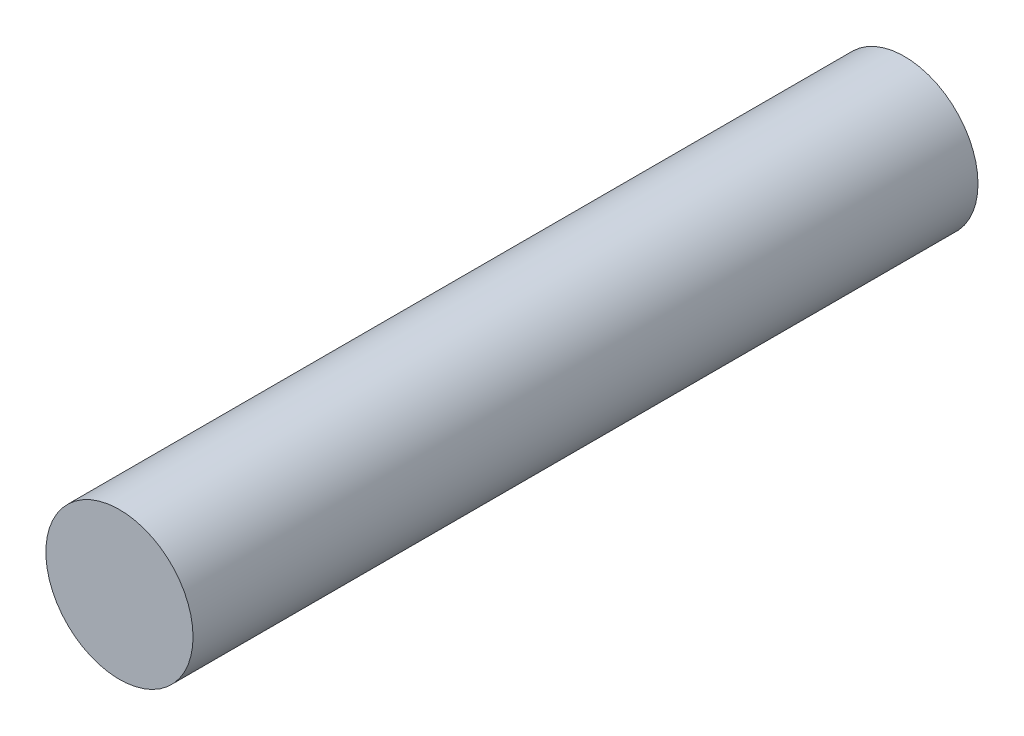
from build123d import *

# Parameters (mm, degrees)
SKETCH1_R           = 2.38125
BOSS_EXTRUDE1_DEPTH = 25.4


with BuildPart() as part:
    # Sketch1 → Boss-Extrude1 (new body)
    with BuildSketch(Plane.XY):
        Circle(SKETCH1_R)
    extrude(amount=-BOSS_EXTRUDE1_DEPTH)


solid = part.part
